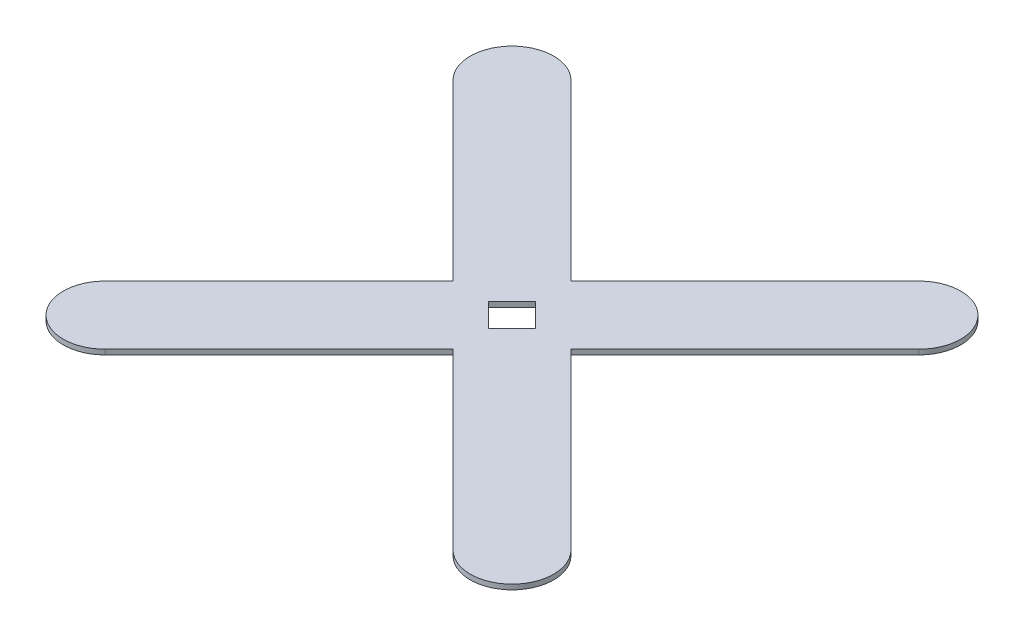
from build123d import *

# Parameters (mm, degrees)
BOSS_EXTRUDE2_DEPTH = 3
CUT_EXTRUDE2_DEPTH  = 5


with BuildPart() as part:
    # Sketch2 → Boss-Extrude2 (new body)
    with BuildSketch(Plane(origin=(0, 0, 0), x_dir=(1, 0, 0), z_dir=(0, 1, 0))):
        with BuildLine():
            Line((104.32233047, -139.67766953), (0, -35.355339059))
            Line((0, -35.355339059), (-104.32233047, -139.67766953))
            ThreePointArc((-104.32233047, -139.67766953), (-139.67766953, -139.67766953), (-139.67766953, -104.32233047))
            Line((-139.67766953, -104.32233047), (-35.355339059, 0))
            Line((-35.355339059, 0), (-139.67766953, 104.32233047))
            ThreePointArc((-139.67766953, 104.32233047), (-139.67766953, 139.67766953), (-104.32233047, 139.67766953))
            Line((-104.32233047, 139.67766953), (0, 35.355339059))
            Line((0, 35.355339059), (104.32233047, 139.67766953))
            ThreePointArc((104.32233047, 139.67766953), (139.67766953, 139.67766953), (139.67766953, 104.32233047))
            Line((139.67766953, 104.32233047), (35.355339059, 0))
            Line((35.355339059, 0), (139.67766953, -104.32233047))
            ThreePointArc((139.67766953, -104.32233047), (139.67766953, -139.67766953), (104.32233047, -139.67766953))
        make_face()
    extrude(amount=BOSS_EXTRUDE2_DEPTH)

    # Sketch6 → Cut-Extrude2 (cut)
    with BuildSketch(Plane(origin=(0, 3, 0), x_dir=(1, 0, 0), z_dir=(0, 1, 0))):
        Polygon((0, -14.142135624), (14.142135624, 0), (0, 14.142135624), (-14.142135624, 0), align=None)
    extrude(amount=-CUT_EXTRUDE2_DEPTH, mode=Mode.SUBTRACT)


solid = part.part
